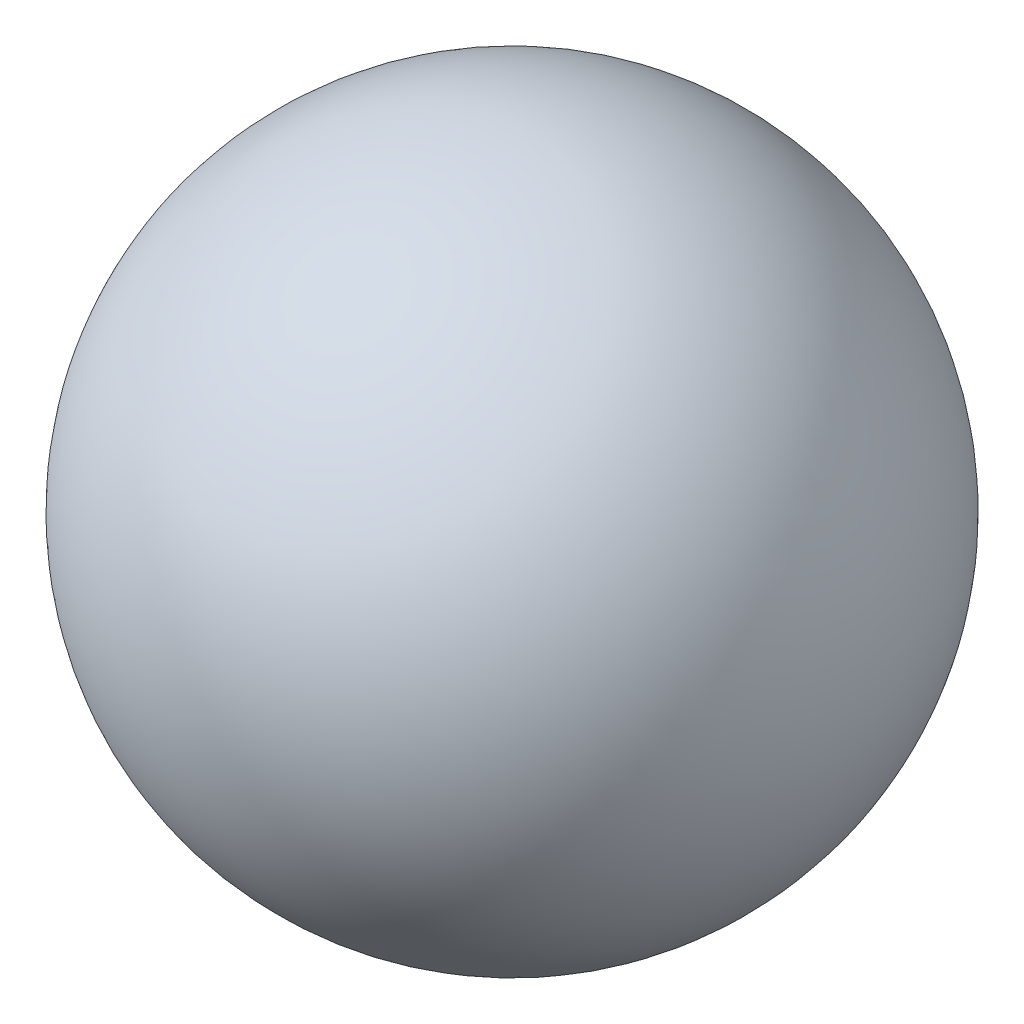
from build123d import *


with BuildPart() as part:
    # Çizim1 → Döndür1 (revolve)
    with BuildSketch(Plane.XY):
        with BuildLine():
            Line((1.5, 0), (-1.5, 0))
            ThreePointArc((-1.5, 0), (0, 1.5), (1.5, 0))
        make_face()
    revolve(axis=Axis((1.5, 0, 0), (-1, 0, 0)))


solid = part.part
